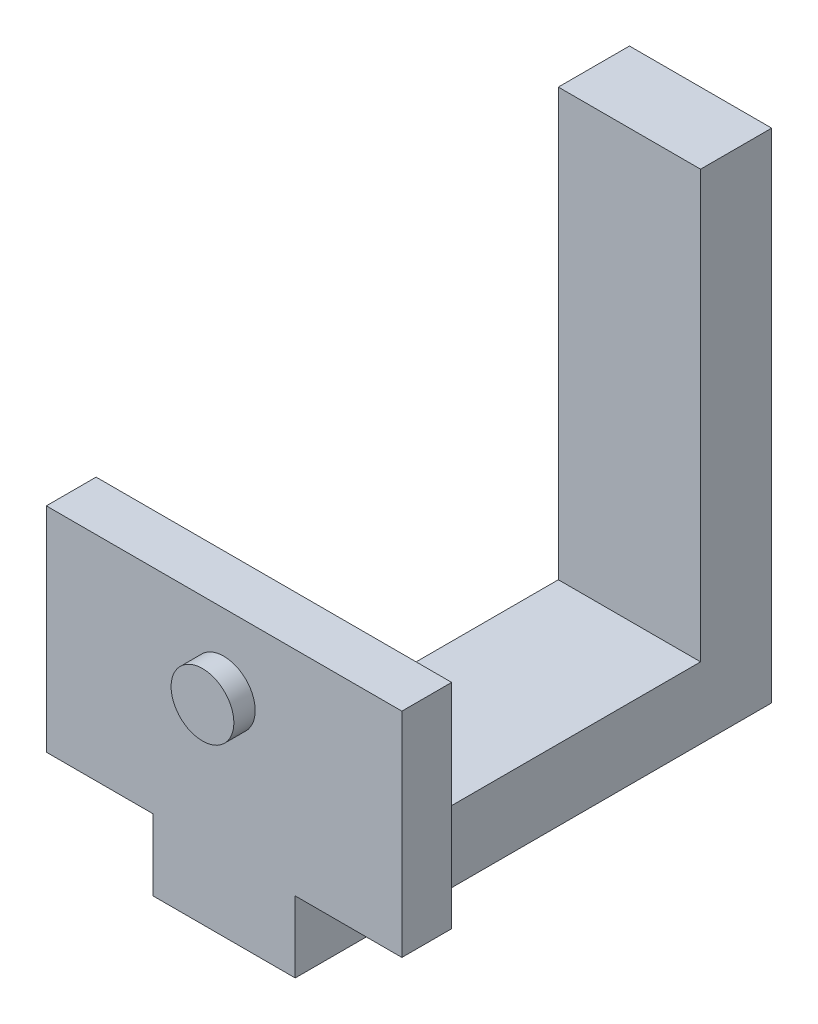
from build123d import *

# Parameters (mm, degrees)
SKETCH1_W           = 20
SKETCH1_H           = 70
BOSS_EXTRUDE1_DEPTH = 10
SKETCH2_W           = 20
SKETCH2_H           = 10
BOSS_EXTRUDE2_DEPTH = 50
SKETCH3_W           = 20
SKETCH3_H           = 10
BOSS_EXTRUDE3_DEPTH = 7
SKETCH4_W           = 15
SKETCH4_H           = 7
SKETCH4_W_2         = 20
BOSS_EXTRUDE4_DEPTH = 30
SKETCH5_R           = 4.414464055
BOSS_EXTRUDE5_DEPTH = 3


with BuildPart() as part:
    # Sketch1 → Boss-Extrude1 (new body)
    with BuildSketch(Plane.XY):
        with Locations((10, 35)):
            Rectangle(SKETCH1_W, SKETCH1_H)
    extrude(amount=BOSS_EXTRUDE1_DEPTH)

    # Sketch2 → Boss-Extrude2 (add)
    with BuildSketch(Plane.XY.offset(10)):
        with Locations((10, 5)):
            Rectangle(SKETCH2_W, SKETCH2_H)
    extrude(amount=BOSS_EXTRUDE2_DEPTH)

    # Sketch3 → Boss-Extrude3 (add)
    with BuildSketch(Plane.XY.offset(60)):
        with Locations((10, 5)):
            Rectangle(SKETCH3_W, SKETCH3_H)
    extrude(amount=BOSS_EXTRUDE3_DEPTH)

    # Sketch4 → Boss-Extrude4 (add)
    with BuildSketch(Plane(origin=(0, 10, 0), x_dir=(1, 0, 0), z_dir=(0, 1, 0))):
        with Locations((-7.5, -63.5)):
            Rectangle(SKETCH4_W, SKETCH4_H)
        with Locations((10, -63.5)):
            Rectangle(SKETCH4_W_2, SKETCH4_H)
        with Locations((27.5, -63.5)):
            Rectangle(SKETCH4_W, SKETCH4_H)
    extrude(amount=BOSS_EXTRUDE4_DEPTH)

    # Sketch5 → Boss-Extrude5 (add)
    with BuildSketch(Plane.XY.offset(67)):
        with Locations((9.957681606, 29.754854133)):
            Circle(SKETCH5_R)
    extrude(amount=BOSS_EXTRUDE5_DEPTH)


solid = part.part
